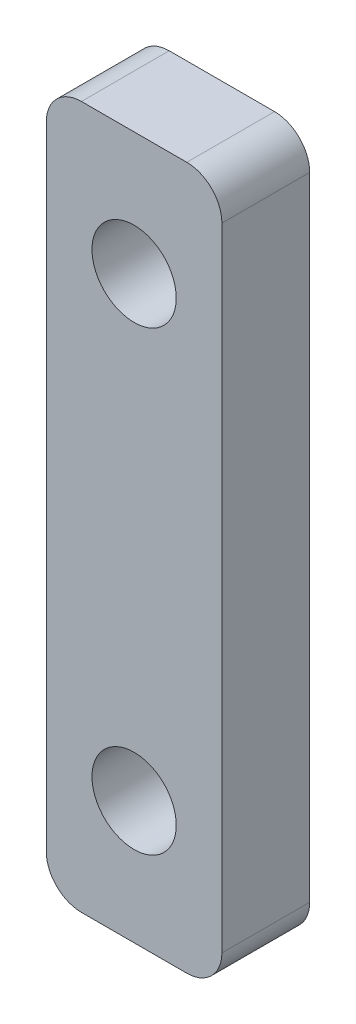
from build123d import *

# Parameters (mm, degrees)
SKETCH1_W           = 10
SKETCH1_H           = 40
SKETCH1_R           = 2.4
BOSS_EXTRUDE1_DEPTH = 5
FILLET1_R           = 2


with BuildPart() as part:
    # Sketch1 → Boss-Extrude1 (new body)
    with BuildSketch(Plane.XY):
        Rectangle(SKETCH1_W, SKETCH1_H)
        with Locations((0, 13)):
            Circle(SKETCH1_R, mode=Mode.SUBTRACT)
        with Locations((0, -13)):
            Circle(SKETCH1_R, mode=Mode.SUBTRACT)
    extrude(amount=BOSS_EXTRUDE1_DEPTH)

    # Fillet1
    fillet1_edges = [part.edges().sort_by_distance(p)[0] for p in [
        (5, -20, 2.5),
        (-5, -20, 2.5),
        (-5, 20, 2.5),
        (5, 20, 2.5),
    ]]
    fillet(fillet1_edges, radius=FILLET1_R)


solid = part.part
